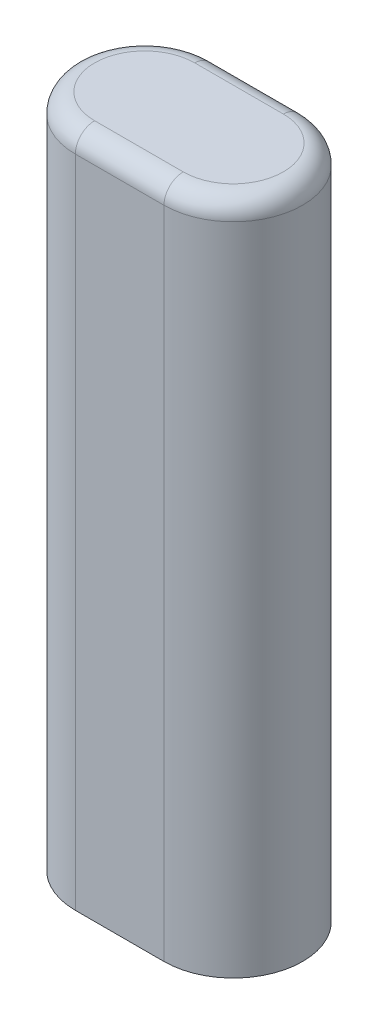
from build123d import *

# Parameters (mm, degrees)
BOSS_EXTRUDE1_DEPTH = 22.225
FILLET1_R           = 0.635
SKETCH2_R           = 1.778
CUT_EXTRUDE3_DEPTH  = 8.255


with BuildPart() as part:
    # Sketch1 → Boss-Extrude1 (new body)
    with BuildSketch(Plane(origin=(0, 0, 0), x_dir=(1, 0, 0), z_dir=(0, 1, 0))):
        with BuildLine():
            Line((-1.4605, 2.286), (1.4605, 2.286))
            ThreePointArc((1.4605, 2.286), (3.7465, 0), (1.4605, -2.286))
            Line((1.4605, -2.286), (-1.4605, -2.286))
            ThreePointArc((-1.4605, -2.286), (-3.7465, 0), (-1.4605, 2.286))
        make_face()
    extrude(amount=BOSS_EXTRUDE1_DEPTH)

    # Fillet1
    fillet1_edges = [part.edges().sort_by_distance(p)[0] for p in [
        (3.7465, 22.225, 0),
        (0, 22.225, -2.286),
        (-3.7465, 22.225, 0),
        (0, 22.225, 2.286),
    ]]
    fillet(fillet1_edges, radius=FILLET1_R)

    # Sketch2 → Cut-Extrude3 (cut)
    with BuildSketch(Plane.XZ):
        Circle(SKETCH2_R)
    extrude(amount=-CUT_EXTRUDE3_DEPTH, mode=Mode.SUBTRACT)


solid = part.part
